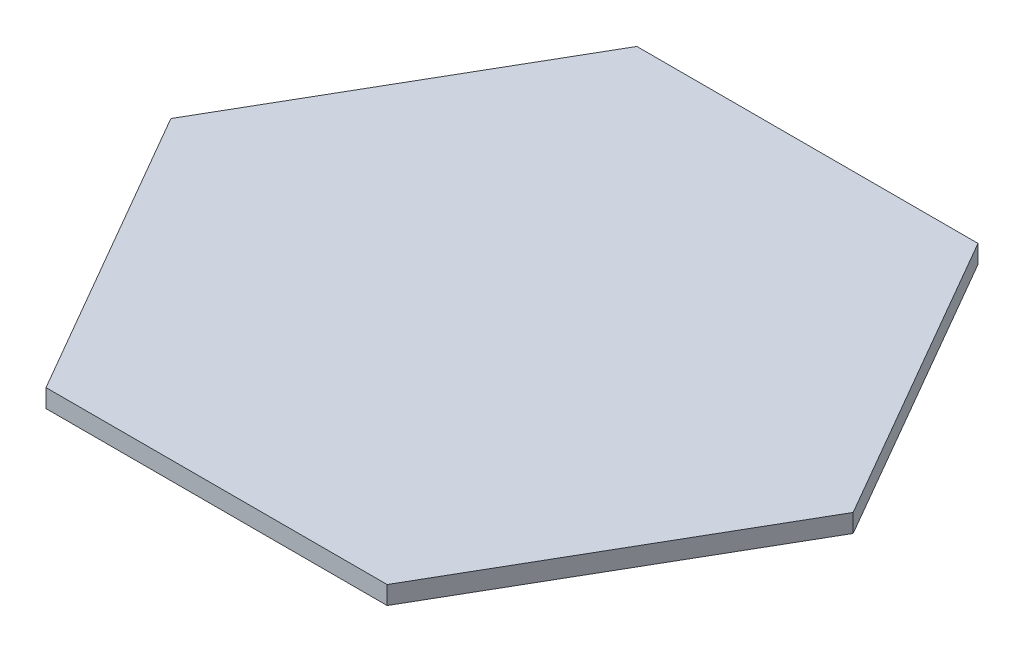
from build123d import *

# Parameters (mm, degrees)
BOSS_EXTRUDE1_DEPTH = 3.175


with BuildPart() as part:
    # Sketch1 → Boss-Extrude1 (new body)
    with BuildSketch(Plane(origin=(0, 0, 0), x_dir=(1, 0, 0), z_dir=(0, 1, 0))):
        Polygon((59.439676901, 0), (29.719838451, 51.476270189), (-29.719838451, 51.476270189), (-59.439676901, 0), (-29.719838451, -51.476270189), (29.719838451, -51.476270189), align=None)
    extrude(amount=BOSS_EXTRUDE1_DEPTH)


solid = part.part
